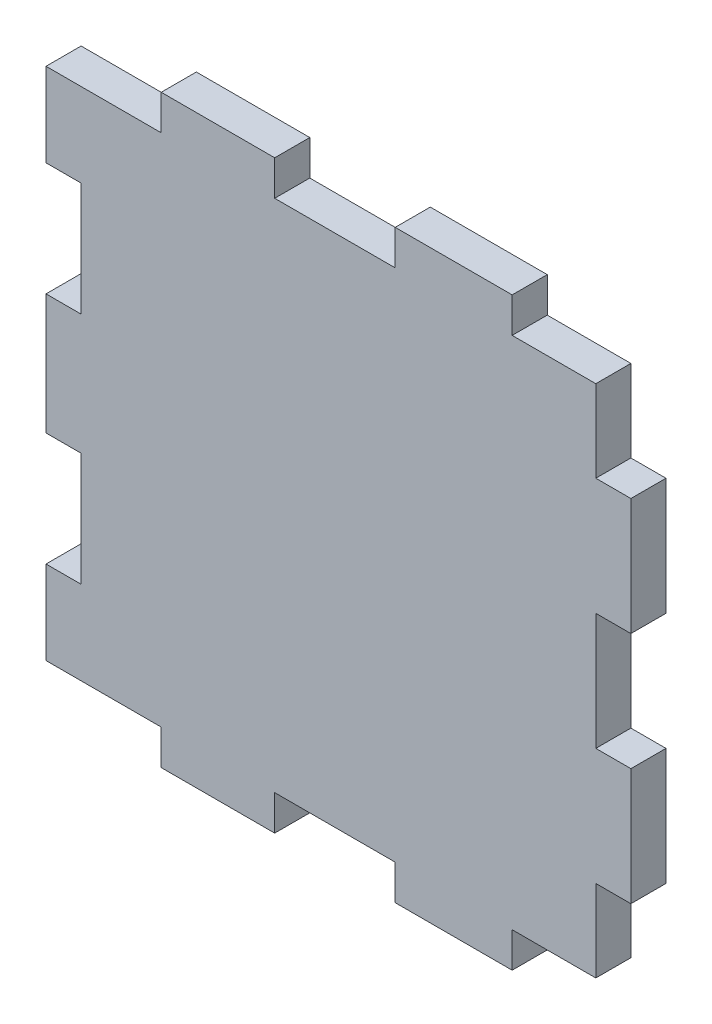
from build123d import *

# Parameters (mm, degrees)
SALIENTE_EXTRUIR1_DEPTH = 3


with BuildPart() as part:
    # Croquis1 → Saliente-Extruir1 (new body)
    with BuildSketch(Plane.XY):
        Polygon((-16.65, 22), (-26.5, 22), (-26.5, 14.85), (-23.5, 14.85), (-23.5, 5.15), (-26.5, 5.15), (-26.5, -5.15), (-23.5, -5.15), (-23.5, -14.85), (-26.5, -14.85), (-26.5, -22), (-16.65, -22), (-16.65, -25), (-6.95, -25), (-6.95, -22), (3.35, -22), (3.35, -25), (13.35, -25), (13.35, -22), (20.5, -22), (20.5, -15), (23.5, -15), (23.5, -5), (20.5, -5), (20.5, 5), (23.5, 5), (23.5, 15), (20.5, 15), (20.5, 22), (13.35, 22), (13.35, 25), (3.35, 25), (3.35, 22), (-6.95, 22), (-6.95, 25), (-16.65, 25), align=None)
    extrude(amount=SALIENTE_EXTRUIR1_DEPTH)


solid = part.part
